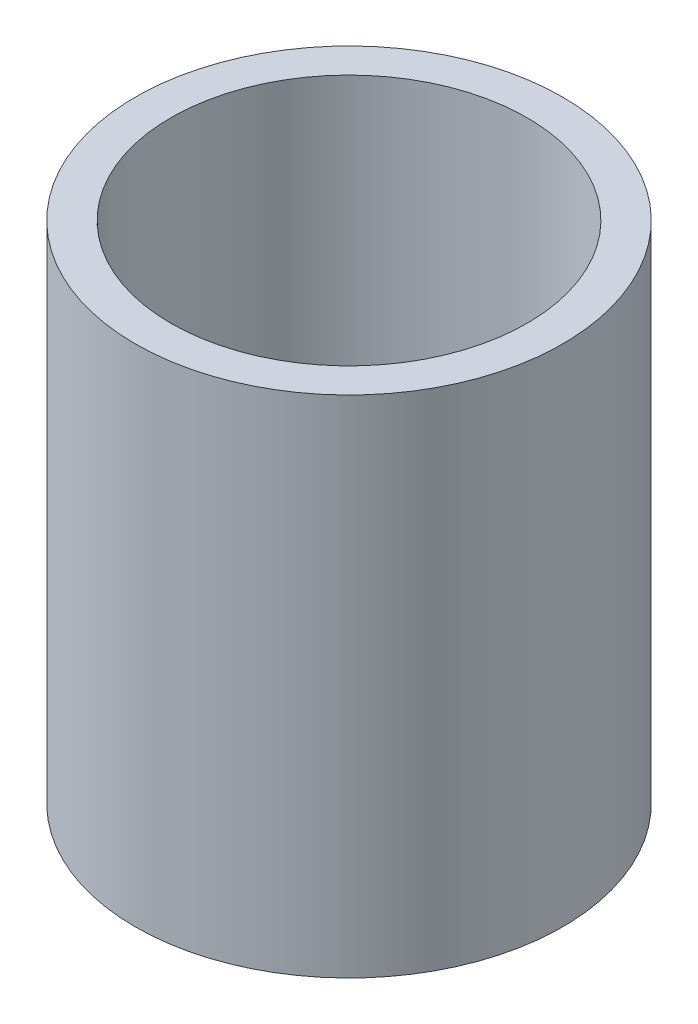
from build123d import *

# Parameters (mm, degrees)
SKETCH1_R           = 38.1
BOSS_EXTRUDE1_DEPTH = 90
SKETCH5_R           = 31.75
CUT_EXTRUDE1_DEPTH  = 77.300000086


with BuildPart() as part:
    # Sketch1 → Boss-Extrude1 (new body)
    with BuildSketch(Plane(origin=(0, 0, 0), x_dir=(1, 0, 0), z_dir=(0, 1, 0))):
        Circle(SKETCH1_R)
    extrude(amount=BOSS_EXTRUDE1_DEPTH)

    # Sketch5 → Cut-Extrude1 (cut)
    with BuildSketch(Plane(origin=(0, 90, 0), x_dir=(1, 0, 0), z_dir=(0, 1, 0))):
        Circle(SKETCH5_R)
    extrude(amount=-CUT_EXTRUDE1_DEPTH, mode=Mode.SUBTRACT)


solid = part.part
